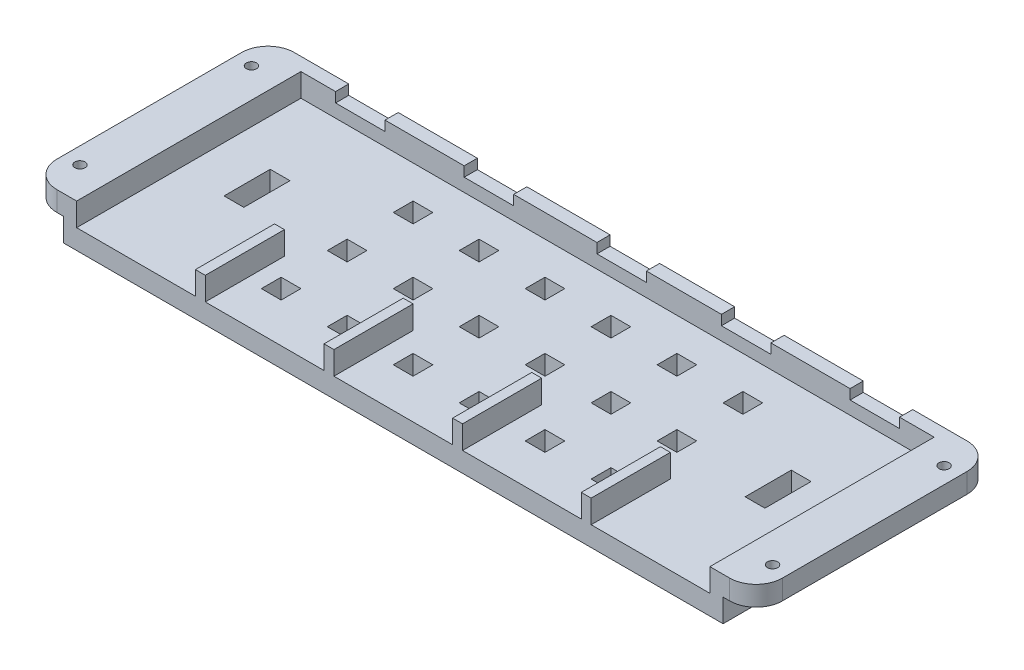
from build123d import *

# Parameters (mm, degrees)
SKETCH1_W           = 100
SKETCH1_H           = 36
BOSS_EXTRUDE1_DEPTH = 3
SKETCH2_W           = 100
SKETCH2_H           = 36
SKETCH2_W_2         = 96
SKETCH2_H_2         = 32
BOSS_EXTRUDE2_DEPTH = 3.5
SKETCH4_W           = 18
SKETCH4_H           = 2
SKETCH4_W_2         = 7.5
CUT_EXTRUDE1_DEPTH  = 3.5
SKETCH5_W           = 1.5
SKETCH5_H           = 3.5
BOSS_EXTRUDE3_DEPTH = 10
SKETCH6_W           = 7.5
SKETCH6_H           = 2
BOSS_EXTRUDE4_DEPTH = 2
SKETCH7_W           = 36
SKETCH7_H           = 3
BOSS_EXTRUDE5_DEPTH = 5
SKETCH8_W           = 36
SKETCH8_H           = 3
BOSS_EXTRUDE6_DEPTH = 5
SKETCH9_R           = 0.775
CUT_EXTRUDE2_DEPTH  = 4
SKETCH10_R          = 1.275
CUT_EXTRUDE3_DEPTH  = 1
FILLET1_R           = 4
BOSS_EXTRUDE7_DEPTH = 3
FILLET2_R           = 2
SKETCH12_W          = 3
SKETCH12_H          = 3
SKETCH12_H_2        = 7
CUT_EXTRUDE4_DEPTH  = 7.5


with BuildPart() as part:
    # Sketch1 → Boss-Extrude1 (new body)
    with BuildSketch(Plane(origin=(0, 0, 0), x_dir=(1, 0, 0), z_dir=(0, 1, 0))):
        with Locations((13.082251082, -9.558441558)):
            Rectangle(SKETCH1_W, SKETCH1_H)
    extrude(amount=BOSS_EXTRUDE1_DEPTH)

    # Sketch2 → Boss-Extrude2 (add)
    with BuildSketch(Plane(origin=(0, 3, 0), x_dir=(1, 0, 0), z_dir=(0, 1, 0))):
        with Locations((13.082251082, -9.558441558)):
            Rectangle(SKETCH2_W, SKETCH2_H)
        with Locations((13.082251082, -9.558441558)):
            Rectangle(SKETCH2_W_2, SKETCH2_H_2, mode=Mode.SUBTRACT)
    extrude(amount=BOSS_EXTRUDE2_DEPTH)

    # Sketch4 → Cut-Extrude1 (cut)
    with BuildSketch(Plane(origin=(0, 6.5, 0), x_dir=(1, 0, 0), z_dir=(0, 1, 0))):
        with Locations((-25.917748918, -26.558441558)):
            Rectangle(SKETCH4_W, SKETCH4_H)
        with Locations((-6.417748918, -26.558441558)):
            Rectangle(SKETCH4_W, SKETCH4_H)
        with Locations((13.082251082, -26.558441558)):
            Rectangle(SKETCH4_W, SKETCH4_H)
        with Locations((32.582251082, -26.558441558)):
            Rectangle(SKETCH4_W, SKETCH4_H)
        with Locations((52.082251082, -26.558441558)):
            Rectangle(SKETCH4_W, SKETCH4_H)
        with Locations((-25.917748918, 7.441558442)):
            Rectangle(SKETCH4_W_2, SKETCH4_H)
        with Locations((-6.417748918, 7.441558442)):
            Rectangle(SKETCH4_W_2, SKETCH4_H)
        with Locations((13.708384448, 7.441558442)):
            Rectangle(SKETCH4_W_2, SKETCH4_H)
        with Locations((32.582251082, 7.441558442)):
            Rectangle(SKETCH4_W_2, SKETCH4_H)
        with Locations((52.082251082, 7.441558442)):
            Rectangle(SKETCH4_W_2, SKETCH4_H)
    extrude(amount=-CUT_EXTRUDE1_DEPTH, mode=Mode.SUBTRACT)

    # Sketch5 → Boss-Extrude3 (add)
    with BuildSketch(Plane(origin=(0, 0, 25.558441558), x_dir=(-1, 0, 0), z_dir=(0, 0, -1))):
        with Locations((16.167748918, 4.75)):
            Rectangle(SKETCH5_W, SKETCH5_H)
        with Locations((-3.332251082, 4.75)):
            Rectangle(SKETCH5_W, SKETCH5_H)
        with Locations((-22.832251082, 4.75)):
            Rectangle(SKETCH5_W, SKETCH5_H)
        with Locations((-42.332251082, 4.75)):
            Rectangle(SKETCH5_W, SKETCH5_H)
    extrude(amount=BOSS_EXTRUDE3_DEPTH)

    # Sketch6 → Boss-Extrude4 (add)
    with BuildSketch(Plane(origin=(0, 3, 0), x_dir=(1, 0, 0), z_dir=(0, 1, 0))):
        with Locations((-25.917748918, 7.441558442)):
            Rectangle(SKETCH6_W, SKETCH6_H)
        with Locations((-6.417748918, 7.441558442)):
            Rectangle(SKETCH6_W, SKETCH6_H)
        with Locations((13.708384448, 7.441558442)):
            Rectangle(SKETCH6_W, SKETCH6_H)
        with Locations((32.582251082, 7.441558442)):
            Rectangle(SKETCH6_W, SKETCH6_H)
        with Locations((52.082251082, 7.441558442)):
            Rectangle(SKETCH6_W, SKETCH6_H)
    extrude(amount=BOSS_EXTRUDE4_DEPTH)

    # Sketch7 → Boss-Extrude5 (add)
    with BuildSketch(Plane.ZY.offset(36.917748918)):
        with Locations((9.558441558, 5)):
            Rectangle(SKETCH7_W, SKETCH7_H)
    extrude(amount=BOSS_EXTRUDE5_DEPTH)

    # Sketch8 → Boss-Extrude6 (add)
    with BuildSketch(Plane(origin=(63.082251082, 0, 0), x_dir=(0, 0, -1), z_dir=(1, 0, 0))):
        with Locations((-9.558441558, 5)):
            Rectangle(SKETCH8_W, SKETCH8_H)
    extrude(amount=BOSS_EXTRUDE6_DEPTH)

    # Sketch9 → Cut-Extrude2 (cut, through all)
    with BuildSketch(Plane.XZ.offset(-3.5)):
        with Locations((-39.417748918, 22.558441558)):
            Circle(SKETCH9_R)
        with Locations((-39.417748918, -3.441558442)):
            Circle(SKETCH9_R)
        with Locations((65.582251082, 22.558441558)):
            Circle(SKETCH9_R)
        with Locations((65.582251082, -3.441558442)):
            Circle(SKETCH9_R)
    extrude(amount=-CUT_EXTRUDE2_DEPTH, mode=Mode.SUBTRACT)

    # Sketch10 → Cut-Extrude3 (cut)
    with BuildSketch(Plane.XZ.offset(-3.5)):
        with Locations((-39.417748918, 22.558441558)):
            Circle(SKETCH10_R)
        with Locations((-39.417748918, -3.441558442)):
            Circle(SKETCH10_R)
        with Locations((65.582251082, 22.558441558)):
            Circle(SKETCH10_R)
        with Locations((65.582251082, -3.441558442)):
            Circle(SKETCH10_R)
    extrude(amount=-CUT_EXTRUDE3_DEPTH, mode=Mode.SUBTRACT)

    # Fillet1
    fillet1_edges = [part.edges().sort_by_distance(p)[0] for p in [
        (-41.917748918, 5, -8.441558442),
        (-41.917748918, 5, 27.558441558),
        (68.082251082, 5, -8.441558442),
        (68.082251082, 5, 27.558441558),
    ]]
    fillet(fillet1_edges, radius=FILLET1_R)

    # Sketch11 → Boss-Extrude7 (add)
    with BuildSketch(Plane.XZ):
        with BuildLine():
            Line((-31.917748918, 22.558441558), (-21.917748918, 22.558441558))
            ThreePointArc((-21.917748918, 22.558441558), (-19.417748918, 20.058441558), (-21.917748918, 17.558441558))
            Line((-21.917748918, 17.558441558), (-31.917748918, 17.558441558))
            ThreePointArc((-31.917748918, 17.558441558), (-34.417748918, 20.058441558), (-31.917748918, 22.558441558))
        make_face()
        with BuildLine():
            Line((48.082251082, 22.558441558), (58.082251082, 22.558441558))
            ThreePointArc((58.082251082, 22.558441558), (60.582251082, 20.058441558), (58.082251082, 17.558441558))
            Line((58.082251082, 17.558441558), (48.082251082, 17.558441558))
            ThreePointArc((48.082251082, 17.558441558), (45.582251082, 20.058441558), (48.082251082, 22.558441558))
        make_face()
        with BuildLine():
            Line((48.082251082, 1.558441558), (58.082251082, 1.558441558))
            ThreePointArc((58.082251082, 1.558441558), (60.582251082, -0.941558442), (58.082251082, -3.441558442))
            Line((58.082251082, -3.441558442), (48.082251082, -3.441558442))
            ThreePointArc((48.082251082, -3.441558442), (45.582251082, -0.941558442), (48.082251082, 1.558441558))
        make_face()
        with BuildLine():
            Line((-31.917748918, 1.558441558), (-21.917748918, 1.558441558))
            ThreePointArc((-21.917748918, 1.558441558), (-19.417748918, -0.941558442), (-21.917748918, -3.441558442))
            Line((-21.917748918, -3.441558442), (-31.917748918, -3.441558442))
            ThreePointArc((-31.917748918, -3.441558442), (-34.417748918, -0.941558442), (-31.917748918, 1.558441558))
        make_face()
    extrude(amount=BOSS_EXTRUDE7_DEPTH)

    # Fillet2
    fillet2_edges = [part.edges().sort_by_distance(p)[0] for p in [
        (-34.417748918, -3, 20.058441558),
        (-26.917748918, -3, 17.558441558),
        (-19.417748918, -3, 20.058441558),
        (-26.917748918, -3, 22.558441558),
        (45.582251082, -3, 20.058441558),
        (53.082251082, -3, 17.558441558),
        (60.582251082, -3, 20.058441558),
        (53.082251082, -3, 22.558441558),
        (45.582251082, -3, -0.941558442),
        (53.082251082, -3, -3.441558442),
        (60.582251082, -3, -0.941558442),
        (53.082251082, -3, 1.558441558),
        (-34.417748918, -3, -0.941558442),
        (-26.917748918, -3, -3.441558442),
        (-19.417748918, -3, -0.941558442),
        (-26.917748918, -3, 1.558441558),
    ]]
    fillet(fillet2_edges, radius=FILLET2_R)

    # Sketch12 → Cut-Extrude4 (cut, through all)
    with BuildSketch(Plane.XZ):
        with Locations((-11.417748918, 20.058441558)):
            Rectangle(SKETCH12_W, SKETCH12_H)
        with Locations((-1.417748918, 20.058441558)):
            Rectangle(SKETCH12_W, SKETCH12_H)
        with Locations((8.582251082, 20.058441558)):
            Rectangle(SKETCH12_W, SKETCH12_H)
        with Locations((18.582251082, 20.058441558)):
            Rectangle(SKETCH12_W, SKETCH12_H)
        with Locations((28.582251082, 20.058441558)):
            Rectangle(SKETCH12_W, SKETCH12_H)
        with Locations((38.582251082, 20.058441558)):
            Rectangle(SKETCH12_W, SKETCH12_H)
        with Locations((-1.417748918, 10.058441558)):
            Rectangle(SKETCH12_W, SKETCH12_H)
        with Locations((8.582251082, 10.058441558)):
            Rectangle(SKETCH12_W, SKETCH12_H)
        with Locations((18.582251082, 10.058441558)):
            Rectangle(SKETCH12_W, SKETCH12_H)
        with Locations((28.582251082, 10.058441558)):
            Rectangle(SKETCH12_W, SKETCH12_H)
        with Locations((38.582251082, 10.058441558)):
            Rectangle(SKETCH12_W, SKETCH12_H)
        with Locations((-1.417748918, 0.058441558)):
            Rectangle(SKETCH12_W, SKETCH12_H)
        with Locations((8.582251082, 0.058441558)):
            Rectangle(SKETCH12_W, SKETCH12_H)
        with Locations((18.582251082, 0.058441558)):
            Rectangle(SKETCH12_W, SKETCH12_H)
        with Locations((28.582251082, 0.058441558)):
            Rectangle(SKETCH12_W, SKETCH12_H)
        with Locations((38.582251082, 0.058441558)):
            Rectangle(SKETCH12_W, SKETCH12_H)
        with Locations((-11.417748918, 10.058441558)):
            Rectangle(SKETCH12_W, SKETCH12_H)
        with Locations((-11.417748918, 0.058441558)):
            Rectangle(SKETCH12_W, SKETCH12_H)
        with Locations((-26.417748918, 8.715104748)):
            Rectangle(SKETCH12_W, SKETCH12_H_2)
        with Locations((52.582251082, 8.715104748)):
            Rectangle(SKETCH12_W, SKETCH12_H_2)
    extrude(amount=-CUT_EXTRUDE4_DEPTH, mode=Mode.SUBTRACT)


solid = part.part
